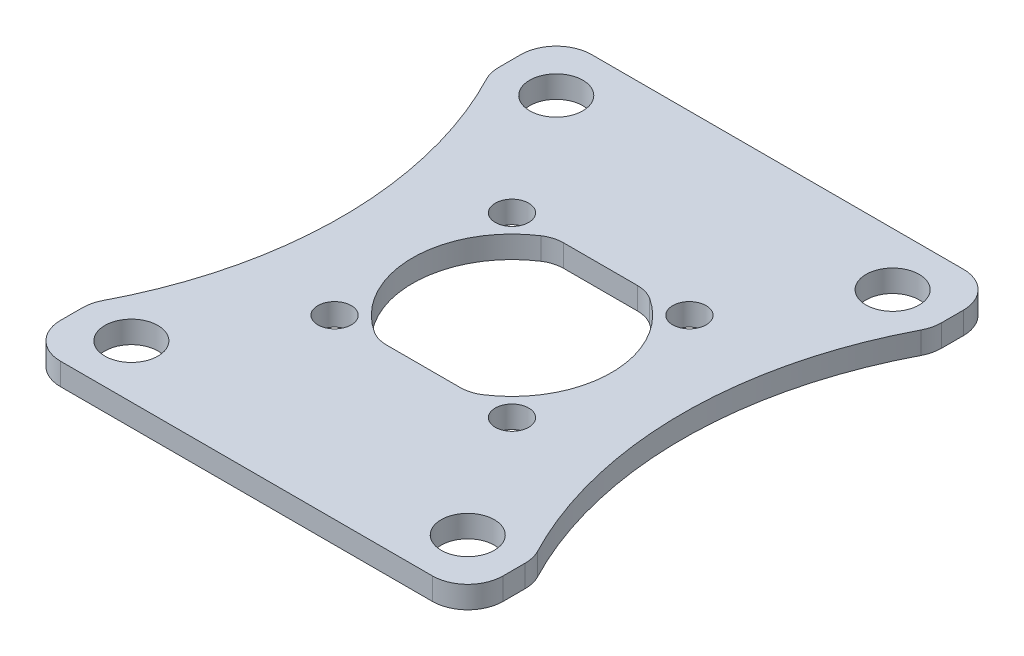
from build123d import *

# Parameters (mm, degrees)
SKETCH1_W           = 31.75
SKETCH1_H           = 38.1
SKETCH1_R           = 7.1374
SKETCH1_R_2         = 1.2
SKETCH1_R_3         = 1.905
BOSS_EXTRUDE1_DEPTH = 1.5875
BOSS_EXTRUDE3_DEPTH = 1.5875
CUT_EXTRUDE1_DEPTH  = 2.5875
FILLET3_R           = 2.54
FILLET2_R           = 2.286


with BuildPart() as part:
    # Sketch1 → Boss-Extrude1 (new body)
    with BuildSketch(Plane(origin=(0, 0, 0), x_dir=(1, 0, 0), z_dir=(0, 1, 0))):
        Rectangle(SKETCH1_W, SKETCH1_H)
        Circle(SKETCH1_R, mode=Mode.SUBTRACT)
        with Locations((-6.363961031, -6.363961031)):
            Circle(SKETCH1_R_2, mode=Mode.SUBTRACT)
        with Locations((-6.363961031, 6.363961031)):
            Circle(SKETCH1_R_2, mode=Mode.SUBTRACT)
        with Locations((6.363961031, 6.363961031)):
            Circle(SKETCH1_R_2, mode=Mode.SUBTRACT)
        with Locations((6.363961031, -6.363961031)):
            Circle(SKETCH1_R_2, mode=Mode.SUBTRACT)
        with Locations((-12.065, -15.24)):
            Circle(SKETCH1_R_3, mode=Mode.SUBTRACT)
        with Locations((-12.065, 15.24)):
            Circle(SKETCH1_R_3, mode=Mode.SUBTRACT)
        with Locations((12.065, 15.24)):
            Circle(SKETCH1_R_3, mode=Mode.SUBTRACT)
        with Locations((12.065, -15.24)):
            Circle(SKETCH1_R_3, mode=Mode.SUBTRACT)
    extrude(amount=BOSS_EXTRUDE1_DEPTH)

    # Sketch3 → Boss-Extrude3 (add, through all)
    with BuildSketch(Plane(origin=(0, 1.5875, 0), x_dir=(1, 0, 0), z_dir=(0, 1, 0))):
        with BuildLine():
            Line((-3.258830889, 6.35), (3.258830889, 6.35))
            ThreePointArc((3.258830889, 6.35), (0, 7.1374), (-3.258830889, 6.35))
        make_face()
        with BuildLine():
            Line((3.258830889, -6.35), (-3.258830889, -6.35))
            ThreePointArc((-3.258830889, -6.35), (0, -7.1374), (3.258830889, -6.35))
        make_face()
    extrude(amount=-BOSS_EXTRUDE3_DEPTH)

    # Sketch4 → Cut-Extrude1 (cut, through all)
    with BuildSketch(Plane.XZ):
        with BuildLine():
            Line((-15.875, 14.296387236), (-15.875, -14.296387236))
            ThreePointArc((-15.875, -14.296387236), (-12.2174, 0), (-15.875, 14.296387236))
        make_face()
        with BuildLine():
            Line((15.875, -14.296387236), (15.875, 14.296387236))
            ThreePointArc((15.875, 14.296387236), (12.2174, 0), (15.875, -14.296387236))
        make_face()
    extrude(amount=-CUT_EXTRUDE1_DEPTH, mode=Mode.SUBTRACT)

    # Fillet3
    fillet3_edges = [part.edges().sort_by_distance(p)[0] for p in [
        (-15.875, 0.79375, 14.296387236),
        (-15.875, 0.79375, -14.296387236),
        (15.875, 0.79375, 19.05),
        (-15.875, 0.79375, 19.05),
        (15.875, 0.79375, -14.296387236),
        (-15.875, 0.79375, -19.05),
        (15.875, 0.79375, 14.296387236),
        (15.875, 0.79375, -19.05),
    ]]
    fillet(fillet3_edges, radius=FILLET3_R)

    # Fillet2
    fillet2_edges = [part.edges().sort_by_distance(p)[0] for p in [
        (-3.258830889, 0.79375, -6.35),
        (3.258830889, 0.79375, -6.35),
        (3.258830889, 0.79375, 6.35),
        (-3.258830889, 0.79375, 6.35),
    ]]
    fillet(fillet2_edges, radius=FILLET2_R)


solid = part.part
